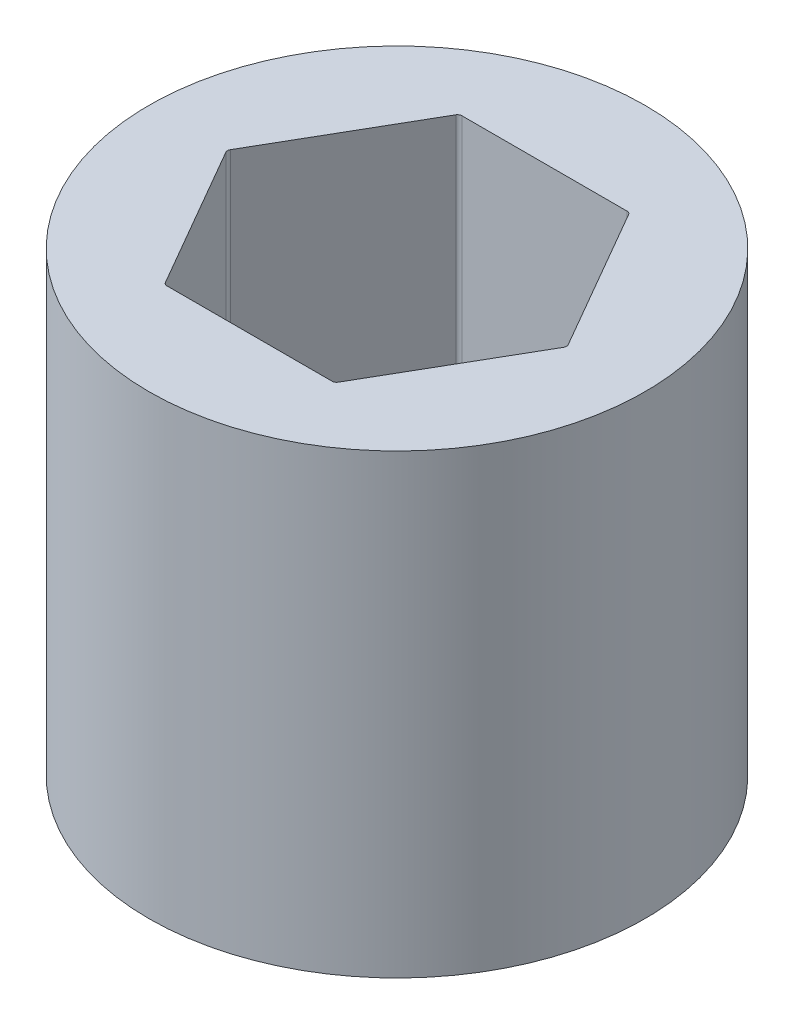
from build123d import *

# Parameters (mm, degrees)
SKETCH1_R           = 11.1125
BOSS_EXTRUDE1_DEPTH = 20.447
FILLET1_R           = 0.2


with BuildPart() as part:
    # Sketch1 → Boss-Extrude1 (new body)
    with BuildSketch(Plane(origin=(0, 0, 0), x_dir=(1, 0, 0), z_dir=(0, 1, 0))):
        Circle(SKETCH1_R)
        Polygon((7.625642355, 0), (3.812821178, 6.604), (-3.812821178, 6.604), (-7.625642355, 0), (-3.812821178, -6.604), (3.812821178, -6.604), align=None, mode=Mode.SUBTRACT)
    extrude(amount=BOSS_EXTRUDE1_DEPTH)

    # Fillet1
    fillet1_edges = [part.edges().sort_by_distance(p)[0] for p in [
        (7.625642355, 10.2235, 0),
        (3.812821178, 10.2235, -6.604),
        (-3.812821178, 10.2235, -6.604),
        (-7.625642355, 10.2235, 0),
        (-3.812821178, 10.2235, 6.604),
        (3.812821178, 10.2235, 6.604),
    ]]
    fillet(fillet1_edges, radius=FILLET1_R)


solid = part.part
